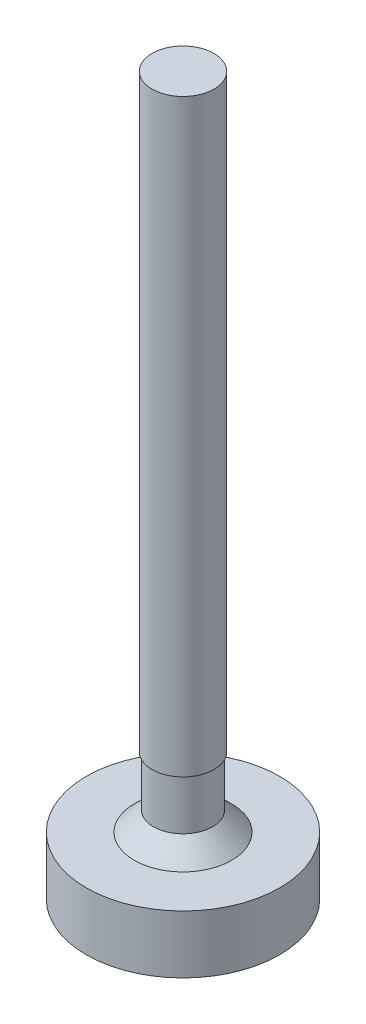
from build123d import *

# Parameters (mm, degrees)
SKETCH_1_R      = 5
EXTRUDE_1_DEPTH = 3
EXTRUDE_START   = 3
SKETCH_1_3_R    = 1.525
EXTRUDE_2_DEPTH = 3.6
EXTRUDE_START_2 = 6.6
SKETCH_1_4_R    = 1.6
EXTRUDE_3_DEPTH = 30.48
CHAMFER_1_SIZE  = 1


with BuildPart() as part:
    # 草图1 → 凸台-拉伸1 (new body)
    with BuildSketch(Plane(origin=(0, 0, 0), x_dir=(1, 0, 0), z_dir=(0, 1, 0))):
        Circle(SKETCH_1_R)
    extrude(amount=EXTRUDE_1_DEPTH)

    # 草图1<3> → 凸台-拉伸2 (add)
    with BuildSketch(Plane(origin=(0, 0, 0), x_dir=(1, 0, 0), z_dir=(0, 1, 0)).offset(EXTRUDE_START)):
        Circle(SKETCH_1_3_R)
    extrude(amount=EXTRUDE_2_DEPTH)

    # 草图1<4> → 凸台-拉伸3 (add)
    with BuildSketch(Plane(origin=(0, 0, 0), x_dir=(1, 0, 0), z_dir=(0, 1, 0)).offset(EXTRUDE_START_2)):
        Circle(SKETCH_1_4_R)
    extrude(amount=EXTRUDE_3_DEPTH)

    # 倒角1
    chamfer_1_edges = [part.edges().sort_by_distance(p)[0] for p in [
        (-1.525, 3, 0),
    ]]
    chamfer(chamfer_1_edges, length=CHAMFER_1_SIZE)


solid = part.part
